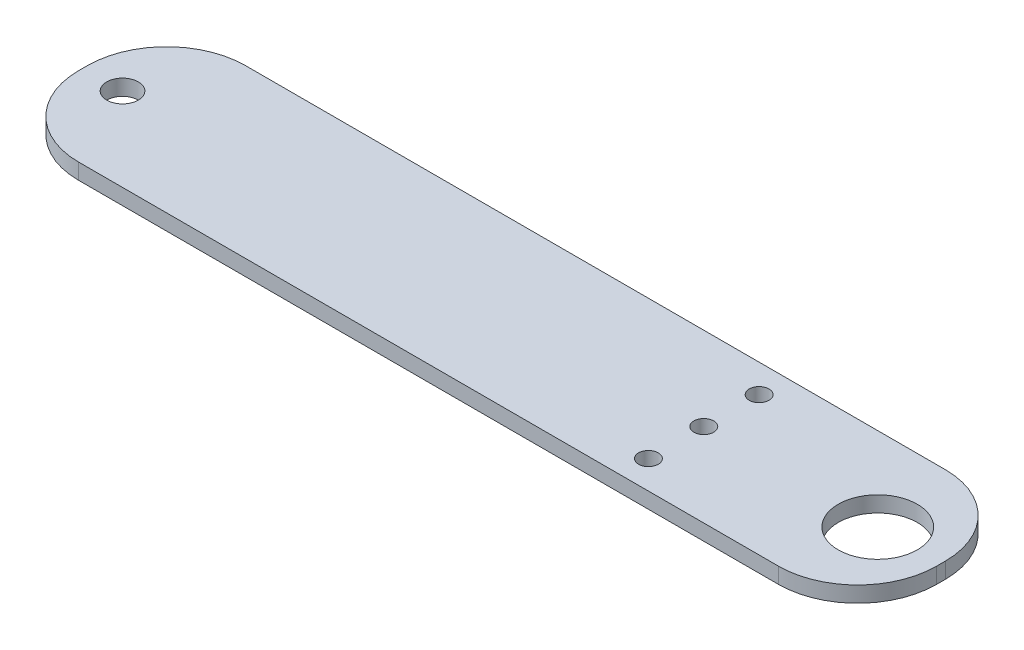
from build123d import *

# Parameters (mm, degrees)
SKETCH1_W           = 108.5
SKETCH1_H           = 21.11675127
SKETCH1_R           = 5
SKETCH1_R_2         = 2
SKETCH1_R_3         = 1.25
BOSS_EXTRUDE1_DEPTH = 2
FILLET1_R           = 10


with BuildPart() as part:
    # Sketch1 → Boss-Extrude1 (new body)
    with BuildSketch(Plane(origin=(0, 0, 0), x_dir=(1, 0, 0), z_dir=(0, 1, 0))):
        with Locations((15.75, 0)):
            Rectangle(SKETCH1_W, SKETCH1_H)
        with Locations((62, 0)):
            Circle(SKETCH1_R, mode=Mode.SUBTRACT)
        with Locations((-33.5, 0)):
            Circle(SKETCH1_R_2, mode=Mode.SUBTRACT)
        with Locations((40, 0)):
            Circle(SKETCH1_R_3, mode=Mode.SUBTRACT)
        with Locations((40, 7)):
            Circle(SKETCH1_R_3, mode=Mode.SUBTRACT)
        with Locations((40, -7)):
            Circle(SKETCH1_R_3, mode=Mode.SUBTRACT)
    extrude(amount=BOSS_EXTRUDE1_DEPTH)

    # Fillet1
    fillet1_edges = [part.edges().sort_by_distance(p)[0] for p in [
        (-38.5, 1, -10.558375635),
        (70, 1, -10.558375635),
        (70, 1, 10.558375635),
        (-38.5, 1, 10.558375635),
    ]]
    fillet(fillet1_edges, radius=FILLET1_R)


solid = part.part
